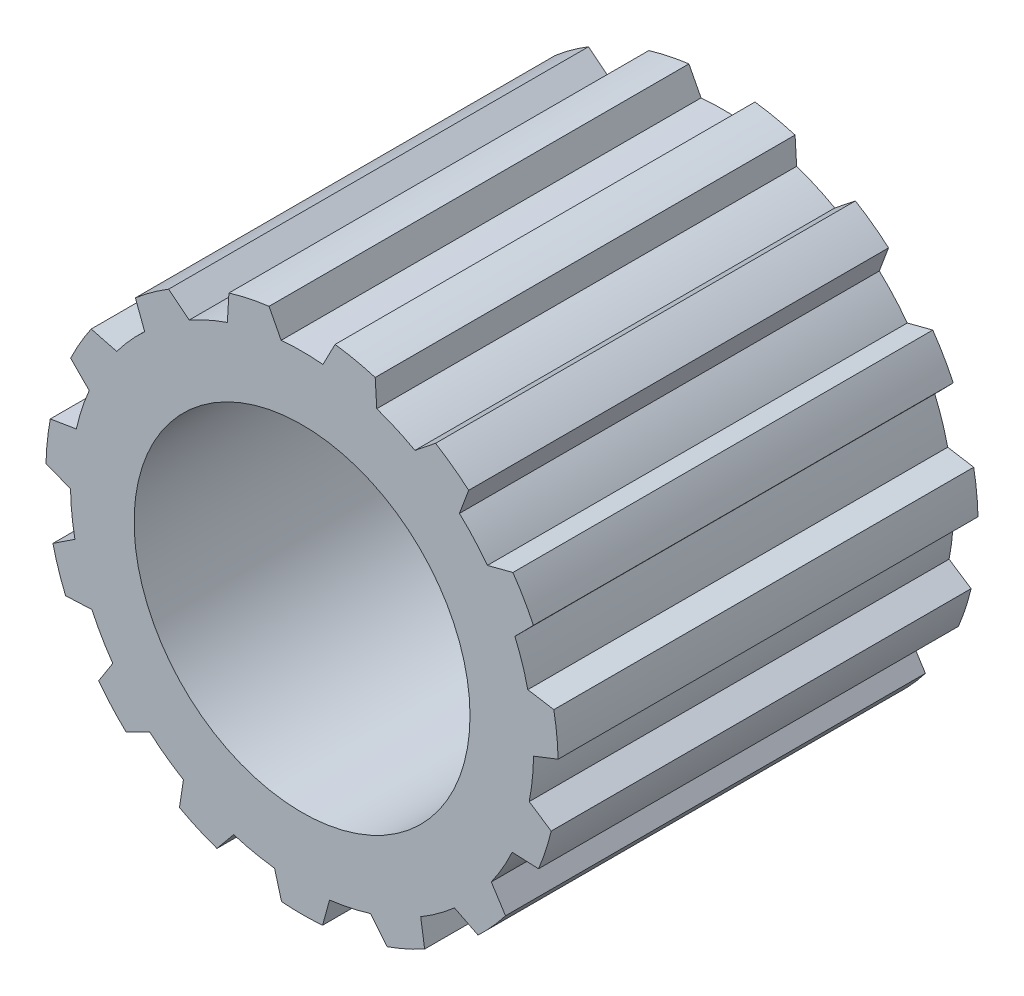
from build123d import *

# Parameters (mm, degrees)
ESQUISSE1_R                  = 6.1
ESQUISSE1_R_2                = 4
BOSS_EXTRU_1_DEPTH           = 10
ENL_V_MAT_EXTRU_1_DEPTH      = 12
ENL_V_MAT_EXTRU_1_DEPTH_BACK = 1


with BuildPart() as part:
    # Esquisse1 → Boss.-Extru.1 (new body)
    with BuildSketch(Plane.XY):
        Circle(ESQUISSE1_R)
        Circle(ESQUISSE1_R_2, mode=Mode.SUBTRACT)
    extrude(amount=BOSS_EXTRU_1_DEPTH)

    # Esquisse3 → Enlèv. mat.-Extru.1 (cut, two sides)
    with BuildSketch(Plane.XY) as enl_v_mat_extru_1_sk:
        with BuildLine():
            Line((-4.507231971, -3.176663454), (-4.845452386, -3.705616166))
            ThreePointArc((-4.845452386, -3.705616166), (-5.282754963, -3.05), (-5.63188393, -2.343476776))
            Line((-5.63188393, -2.343476776), (-5.004687237, -2.315045661))
            ThreePointArc((-5.004687237, -2.315045661), (-4.775431715, -2.757096786), (-4.507231971, -3.176663454))
        make_face()
        with BuildLine():
            Line((-5.409626724, -1.068770068), (-5.933750898, -1.414425779))
            ThreePointArc((-5.933750898, -1.414425779), (-6.066583562, -0.637623626), (-6.098159859, 0.149821))
            Line((-6.098159859, 0.149821), (-5.513623192, -0.079309761))
            ThreePointArc((-5.513623192, -0.079309761), (-5.483986242, -0.57639018), (-5.409626724, -1.068770068))
        make_face()
        with BuildLine():
            ThreePointArc((-4.413997755, 3.304989344), (-4.09784442, 3.689715688), (-3.748272669, 4.044351956))
            Line((-3.748272669, 4.044351956), (-3.969126703, 4.632065761))
            ThreePointArc((-3.969126703, 4.632065761), (-4.533183435, 4.081696699), (-5.021577535, 3.463200696))
            Line((-5.021577535, 3.463200696), (-4.413997755, 3.304989344))
        make_face()
        with BuildLine():
            ThreePointArc((-2.688127328, 4.814592632), (-2.242824583, 5.03746649), (-1.779231332, 5.219259201))
            Line((-1.779231332, 5.219259201), (-1.741946793, 5.845991907))
            ThreePointArc((-1.741946793, 5.845991907), (-2.481093523, 5.572627292), (-3.178828722, 5.206250854))
            Line((-3.178828722, 5.206250854), (-2.688127328, 4.814592632))
        make_face()
        with BuildLine():
            Line((0.497455265, 5.491709115), (0.786431544, 6.049092943))
            ThreePointArc((0.786431544, 6.049092943), (0, 6.1), (-0.786431544, 6.049092943))
            Line((-0.786431544, 6.049092943), (-0.497455265, 5.491709115))
            ThreePointArc((-0.497455265, 5.491709115), (0, 5.514193572), (0.497455265, 5.491709115))
        make_face()
        with BuildLine():
            Line((2.688127328, 4.814592632), (3.178828722, 5.206250854))
            ThreePointArc((3.178828722, 5.206250854), (2.481093523, 5.572627292), (1.741946793, 5.845991907))
            Line((1.741946793, 5.845991907), (1.779231332, 5.219259201))
            ThreePointArc((1.779231332, 5.219259201), (2.242824583, 5.03746649), (2.688127328, 4.814592632))
        make_face()
        with BuildLine():
            Line((3.748272669, 4.044351956), (3.969126703, 4.632065761))
            ThreePointArc((3.969126703, 4.632065761), (4.533183435, 4.081696699), (5.021577535, 3.463200696))
            Line((5.021577535, 3.463200696), (4.413997755, 3.304989344))
            ThreePointArc((4.413997755, 3.304989344), (4.09784442, 3.689715688), (3.748272669, 4.044351956))
        make_face()
        with BuildLine():
            Line((-5.069203609, 2.170139516), (-5.510008549, 2.617213364))
            ThreePointArc((-5.510008549, 2.617213364), (-5.801444749, 1.885003666), (-5.996049973, 1.121331676))
            Line((-5.996049973, 1.121331676), (-5.37664787, 1.223923373))
            ThreePointArc((-5.37664787, 1.223923373), (-5.244309729, 1.703979524), (-5.069203609, 2.170139516))
        make_face()
        with BuildLine():
            ThreePointArc((5.510008549, 2.617213364), (5.801444749, 1.885003666), (5.996049973, 1.121331676))
            Line((5.996049973, 1.121331676), (5.37664787, 1.223923373))
            ThreePointArc((5.37664787, 1.223923373), (5.244309729, 1.703979524), (5.069203609, 2.170139516))
            Line((5.069203609, 2.170139516), (5.510008549, 2.617213364))
        make_face()
        with BuildLine():
            Line((5.513623192, -0.079309761), (6.098159859, 0.149821))
            ThreePointArc((6.098159859, 0.149821), (6.066583562, -0.637623626), (5.933750898, -1.414425779))
            Line((5.933750898, -1.414425779), (5.409626724, -1.068770068))
            ThreePointArc((5.409626724, -1.068770068), (5.483986242, -0.57639018), (5.513623192, -0.079309761))
        make_face()
        with BuildLine():
            Line((5.004687237, -2.315045661), (5.63188393, -2.343476776))
            ThreePointArc((5.63188393, -2.343476776), (5.282754963, -3.05), (4.845452386, -3.705616166))
            Line((4.845452386, -3.705616166), (4.507231971, -3.176663454))
            ThreePointArc((4.507231971, -3.176663454), (4.775431715, -2.757096786), (5.004687237, -2.315045661))
        make_face()
        with BuildLine():
            ThreePointArc((3.630395391, -4.150489134), (3.24116166, -4.46107631), (2.825495864, -4.735282871))
            Line((2.825495864, -4.735282871), (2.919331138, -5.356071854))
            ThreePointArc((2.919331138, -5.356071854), (3.585490039, -4.935003666), (4.191804105, -4.431566128))
            Line((4.191804105, -4.431566128), (3.630395391, -4.150489134))
        make_face()
        with BuildLine():
            ThreePointArc((1.628375202, -5.26827533), (1.146465309, -5.393695212), (0.655205854, -5.47512886))
            Line((0.655205854, -5.47512886), (0.488431014, -6.08041406))
            ThreePointArc((0.488431014, -6.08041406), (1.268261314, -5.966700364), (2.026923269, -5.753397436))
            Line((2.026923269, -5.753397436), (1.628375202, -5.26827533))
        make_face()
        with BuildLine():
            ThreePointArc((-0.655205854, -5.47512886), (-1.146465309, -5.393695212), (-1.628375202, -5.26827533))
            Line((-1.628375202, -5.26827533), (-2.026923269, -5.753397436))
            ThreePointArc((-2.026923269, -5.753397436), (-1.268261314, -5.966700364), (-0.488431014, -6.08041406))
            Line((-0.488431014, -6.08041406), (-0.655205854, -5.47512886))
        make_face()
        with BuildLine():
            ThreePointArc((-2.919331138, -5.356071854), (-3.585490039, -4.935003666), (-4.191804105, -4.431566128))
            Line((-4.191804105, -4.431566128), (-3.630395391, -4.150489134))
            ThreePointArc((-3.630395391, -4.150489134), (-3.24116166, -4.46107631), (-2.825495864, -4.735282871))
            Line((-2.825495864, -4.735282871), (-2.919331138, -5.356071854))
        make_face()
    extrude(amount=ENL_V_MAT_EXTRU_1_DEPTH, mode=Mode.SUBTRACT)
    extrude(enl_v_mat_extru_1_sk.sketch, amount=-ENL_V_MAT_EXTRU_1_DEPTH_BACK, mode=Mode.SUBTRACT)


solid = part.part
